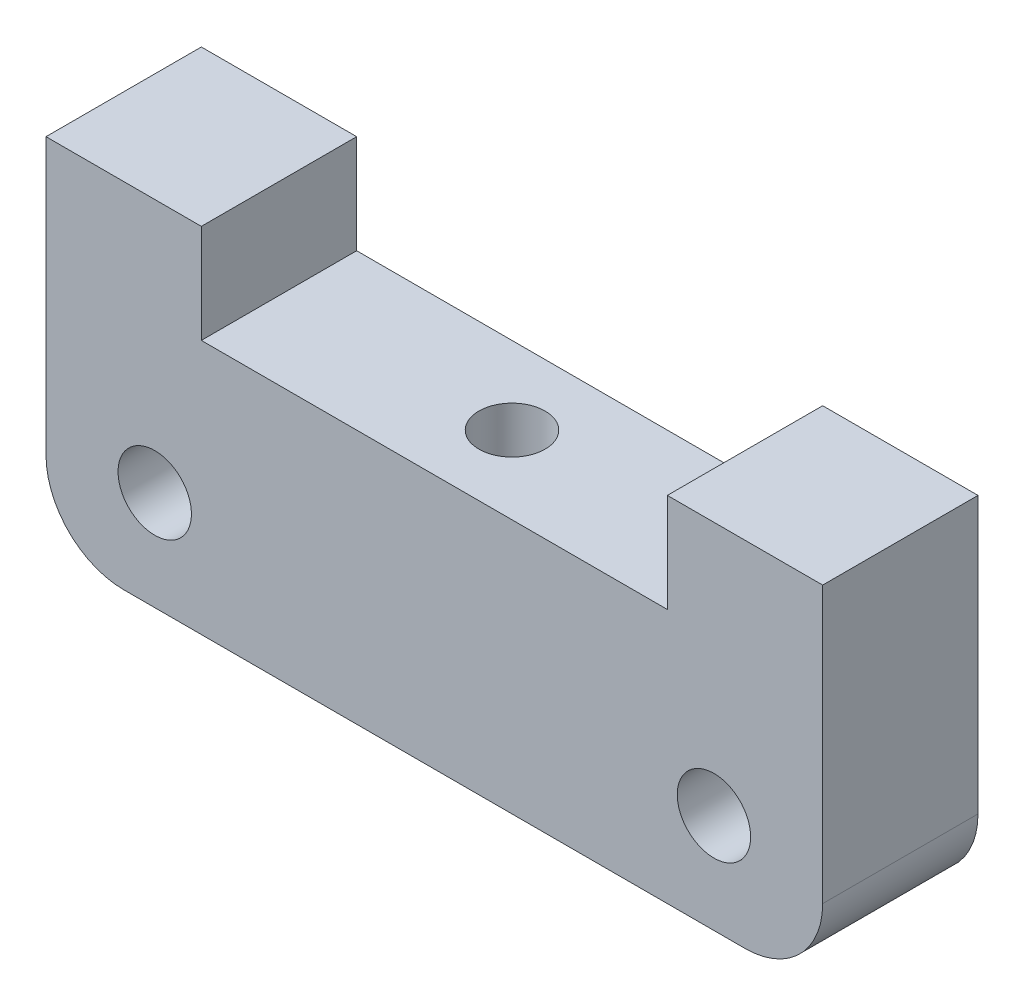
from build123d import *

# Parameters (mm, degrees)
SKETCH1_R           = 1.5
BOSS_EXTRUDE1_DEPTH = 6.35
SKETCH2_R           = 1.35255
CUT_EXTRUDE1_DEPTH  = 15.4526
FILLET1_R           = 3.175


with BuildPart() as part:
    # Sketch1 → Boss-Extrude1 (new body)
    with BuildSketch(Plane.XY):
        Polygon((0, 0), (15.875, 0), (15.875, 14.4526), (9.525, 14.4526), (9.525, 10.414), (0, 10.414), align=None)
        with Locations((11.43, 4.064)):
            Circle(SKETCH1_R, mode=Mode.SUBTRACT)
    boss_extrude1 = extrude(amount=BOSS_EXTRUDE1_DEPTH)

    # Mirror1: Boss-Extrude1 across plane
    add(boss_extrude1.mirror(Plane(origin=(0, 10.414, 6.35), x_dir=(0, 0, 1), z_dir=(1, 0, 0))))

    # Sketch2 → Cut-Extrude1 (cut, through all)
    with BuildSketch(Plane.XZ):
        with Locations((0, 3.175)):
            Circle(SKETCH2_R)
    extrude(amount=-CUT_EXTRUDE1_DEPTH, mode=Mode.SUBTRACT)

    # Fillet1
    fillet1_edges = [part.edges().sort_by_distance(p)[0] for p in [
        (15.875, 0, 3.175),
        (-15.875, 0, 3.175),
    ]]
    fillet(fillet1_edges, radius=FILLET1_R)


solid = part.part
